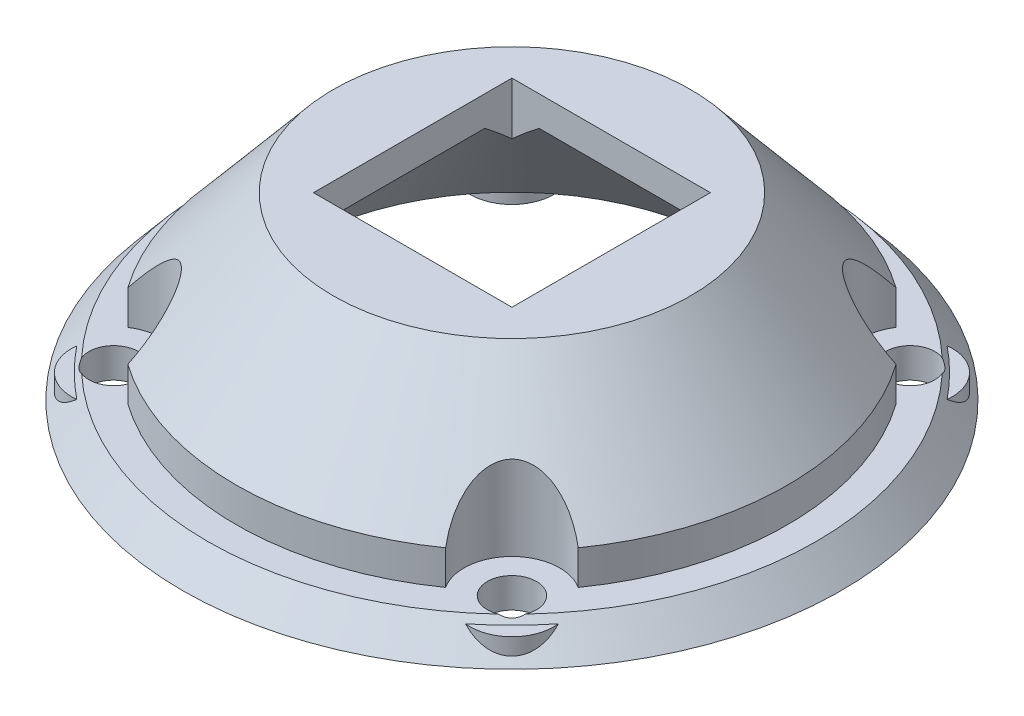
from build123d import *

# Parameters (mm, degrees)
SKETCH1_R           = 55
BOSS_EXTRUDE1_DEPTH = 30
BOSS_EXTRUDE1_TAPER = 40
SKETCH2_R           = 40
CUT_EXTRUDE2_DEPTH  = 31.0000001
CUT_EXTRUDE2_DRAFT  = -38
SKETCH3_R           = 4.1
CUT_EXTRUDE3_DEPTH  = 31.0000001
CUT_EXTRUDE4_START  = -5
SKETCH4_R           = 8
CUT_EXTRUDE4_DEPTH  = 26.0000001
CUT_EXTRUDE5_START  = -5
SKETCH5_OUTSIDE_W   = 143.686
SKETCH5_OUTSIDE_H   = 143.686
SKETCH5_OUTSIDE_R   = 46
CUT_EXTRUDE5_DEPTH  = 26.0000001
SKETCH6_R           = 50
CUT_EXTRUDE6_DEPTH  = 4
SKETCH8_R           = 7
SKETCH8_R_2         = 4.1
BOSS_EXTRUDE3_DEPTH = 4
SKETCH7_W           = 33.12286241
SKETCH7_H           = 33.12286241
CUT_EXTRUDE7_DEPTH  = 31.0000001
SKETCH9_R           = 29.827011065
SKETCH9_W           = 33.12286241
SKETCH9_H           = 33.12286241
BOSS_EXTRUDE4_DEPTH = 5


with BuildPart() as part:
    # Sketch1 → Boss-Extrude1 (new body)
    with BuildSketch(Plane(origin=(0, 0, 0), x_dir=(1, 0, 0), z_dir=(0, 1, 0))):
        Circle(SKETCH1_R)
    extrude(amount=BOSS_EXTRUDE1_DEPTH, taper=BOSS_EXTRUDE1_TAPER)


with BuildPart() as cut_extrude2_tool:
    # Sketch2 → Cut-Extrude2 (with draft: the straight prism first)
    with BuildSketch(Plane.XZ):
        Circle(SKETCH2_R)
    extrude(amount=-CUT_EXTRUDE2_DEPTH)
    # Cut-Extrude2: the draft: its side faces are tilted about the plane it starts from
    cut_extrude2_sides = [cut_extrude2_tool.faces().sort_by_distance(p)[0] for p in [
        (-40, 15.50000005, 0),
    ]]
    draft(cut_extrude2_sides, Plane.XZ, CUT_EXTRUDE2_DRAFT)


with BuildPart() as part_1:
    add(part.part)

    # Cut-Extrude2: cut by cut_extrude2_tool
    add(cut_extrude2_tool.part, mode=Mode.SUBTRACT)

    # Sketch3 → Cut-Extrude3 (cut, through all)
    with BuildSketch(Plane.XZ):
        with Locations(Location((33.234018716, 33.234018716, 0), (0, 0, 270))):  # turned: the seam where the file's is
            Circle(SKETCH3_R)
        with Locations(Location((33.234018716, -33.234018716, 0), (0, 0, 270))):  # turned: the seam where the file's is
            Circle(SKETCH3_R)
        with Locations(Location((-33.234018716, -33.234018716, 0), (0, 0, 270))):  # turned: the seam where the file's is
            Circle(SKETCH3_R)
        with Locations(Location((-33.234018716, 33.234018716, 0), (0, 0, 270))):  # turned: the seam where the file's is
            Circle(SKETCH3_R)
    extrude(amount=-CUT_EXTRUDE3_DEPTH, mode=Mode.SUBTRACT)

    # Sketch4 → Cut-Extrude4 (cut, through all)
    with BuildSketch(Plane.XZ.offset(CUT_EXTRUDE4_START)):
        with Locations((33.234018716, 33.234018716)):
            Circle(SKETCH4_R)
        with Locations((33.234018716, -33.234018716)):
            Circle(SKETCH4_R)
        with Locations((-33.234018716, -33.234018716)):
            Circle(SKETCH4_R)
        with Locations((-33.234018716, 33.234018716)):
            Circle(SKETCH4_R)
    extrude(amount=-CUT_EXTRUDE4_DEPTH, mode=Mode.SUBTRACT)

    # Sketch5 outside → Cut-Extrude5 (cut, through all)
    with BuildSketch(Plane.XZ.offset(CUT_EXTRUDE5_START)):
        Rectangle(SKETCH5_OUTSIDE_W, SKETCH5_OUTSIDE_H)
        Circle(SKETCH5_OUTSIDE_R, mode=Mode.SUBTRACT)
    extrude(amount=-CUT_EXTRUDE5_DEPTH, mode=Mode.SUBTRACT)

    # Sketch6 → Cut-Extrude6 (cut)
    with BuildSketch(Plane.XZ):
        Circle(SKETCH6_R)
    extrude(amount=-CUT_EXTRUDE6_DEPTH, mode=Mode.SUBTRACT)

    # Sketch8 → Boss-Extrude3 (add)
    with BuildSketch(Plane.XZ.offset(-4)):
        with Locations((33.234018716, -33.234018716)):
            Circle(SKETCH8_R)
        with Locations(Location((33.234018716, -33.234018716, 0), (0, 0, 270))):  # turned: the seam where the file's is
            Circle(SKETCH8_R_2, mode=Mode.SUBTRACT)
        with Locations((-33.234018716, -33.234018716)):
            Circle(SKETCH8_R)
        with Locations(Location((-33.234018716, -33.234018716, 0), (0, 0, 270))):  # turned: the seam where the file's is
            Circle(SKETCH8_R_2, mode=Mode.SUBTRACT)
        with Locations((-33.234018716, 33.234018716)):
            Circle(SKETCH8_R)
        with Locations(Location((-33.234018716, 33.234018716, 0), (0, 0, 270))):  # turned: the seam where the file's is
            Circle(SKETCH8_R_2, mode=Mode.SUBTRACT)
        with Locations((33.234018716, 33.234018716)):
            Circle(SKETCH8_R)
        with Locations(Location((33.234018716, 33.234018716, 0), (0, 0, 270))):  # turned: the seam where the file's is
            Circle(SKETCH8_R_2, mode=Mode.SUBTRACT)
    extrude(amount=BOSS_EXTRUDE3_DEPTH)

    # Sketch7 → Cut-Extrude7 (cut, through all)
    with BuildSketch(Plane(origin=(0, 30, 0), x_dir=(1, 0, 0), z_dir=(0, 1, 0))):
        Rectangle(SKETCH7_W, SKETCH7_H)
    extrude(amount=-CUT_EXTRUDE7_DEPTH, mode=Mode.SUBTRACT)

    # Sketch9 → Boss-Extrude4 (add)
    with BuildSketch(Plane(origin=(0, 30, 0), x_dir=(1, 0, 0), z_dir=(0, 1, 0))):
        Circle(SKETCH9_R)
        Rectangle(SKETCH9_W, SKETCH9_H, mode=Mode.SUBTRACT)
    extrude(amount=-BOSS_EXTRUDE4_DEPTH)


solid = part_1.part
